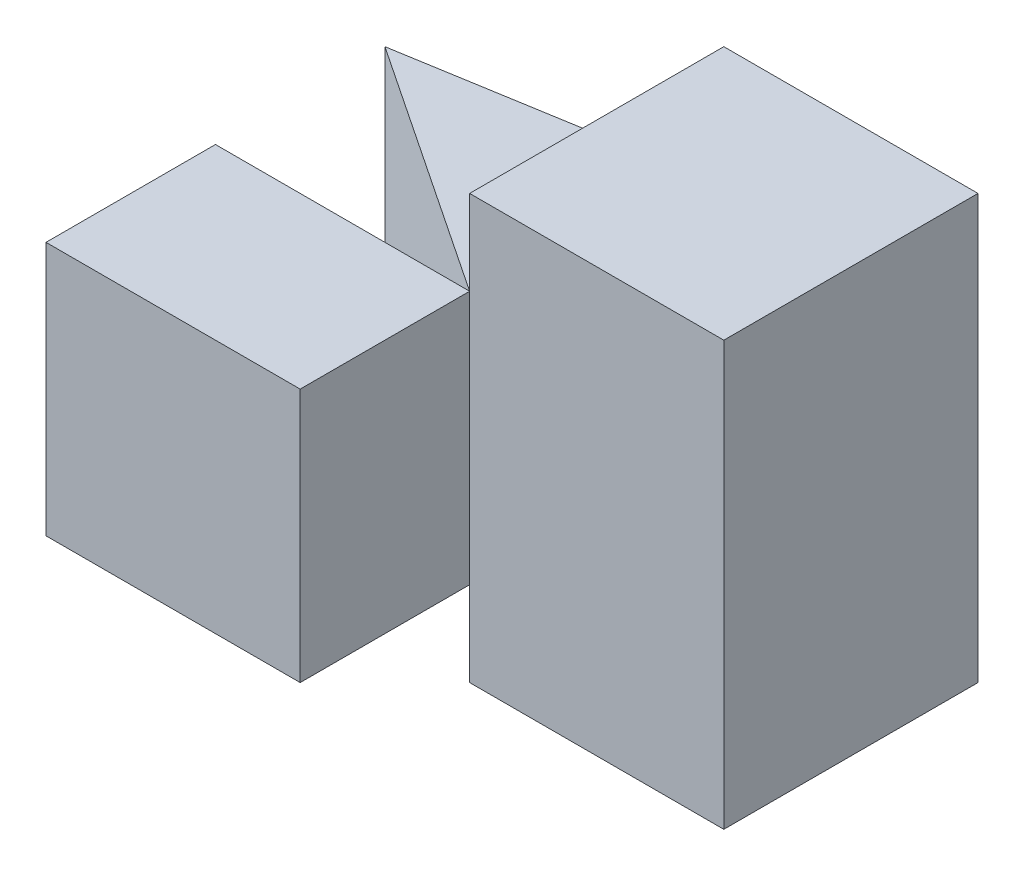
from build123d import *

# Parameters (mm, degrees)
SKETCH1_W           = 3
SKETCH1_H           = 2
SKETCH1_H_2         = 3
BOSS_EXTRUDE3_DEPTH = 5
SKETCH3_W           = 3
SKETCH3_H           = 1
CUT_EXTRUDE2_DEPTH  = 5
CUT_EXTRUDE3_DEPTH  = 5


with BuildPart() as part:
    # Sketch1 → Boss-Extrude3 (new body)
    with BuildSketch(Plane(origin=(0, 0, 0), x_dir=(1, 0, 0), z_dir=(0, 1, 0))):
        with Locations((1.5, 1)):
            Rectangle(SKETCH1_W, SKETCH1_H)
        Polygon((0, 4), (3, 5), (3, 2), align=None)
        with Locations((4.5, 3.5)):
            Rectangle(SKETCH1_W, SKETCH1_H_2)
    extrude(amount=BOSS_EXTRUDE3_DEPTH)

    # Sketch3 → Cut-Extrude2 (cut)
    with BuildSketch(Plane.XY):
        with Locations((1.5, 4.5)):
            Rectangle(SKETCH3_W, SKETCH3_H)
        with Locations((1.5, 0.5)):
            Rectangle(SKETCH3_W, SKETCH3_H)
    extrude(amount=-CUT_EXTRUDE2_DEPTH, mode=Mode.SUBTRACT)

    # 3DSketch1 → Cut-Extrude3 (cut, along a direction that is not the sketch's normal)
    with BuildSketch(Plane(origin=(0, 4, -4), x_dir=(0.8846517369293828, -0.4423258684646914, -0.14744195615489727), z_dir=(0.16439898730535743, 0, 0.9863939238321437))):
        Polygon((0, 0), (5.455352378, 2.690563219), (6.782329983, 0), (1.326977605, -2.690563219), align=None)
    extrude(amount=-CUT_EXTRUDE3_DEPTH, dir=(0.31622776601683794, 0, 0.9486832980505139), mode=Mode.SUBTRACT)


solid = part.part
